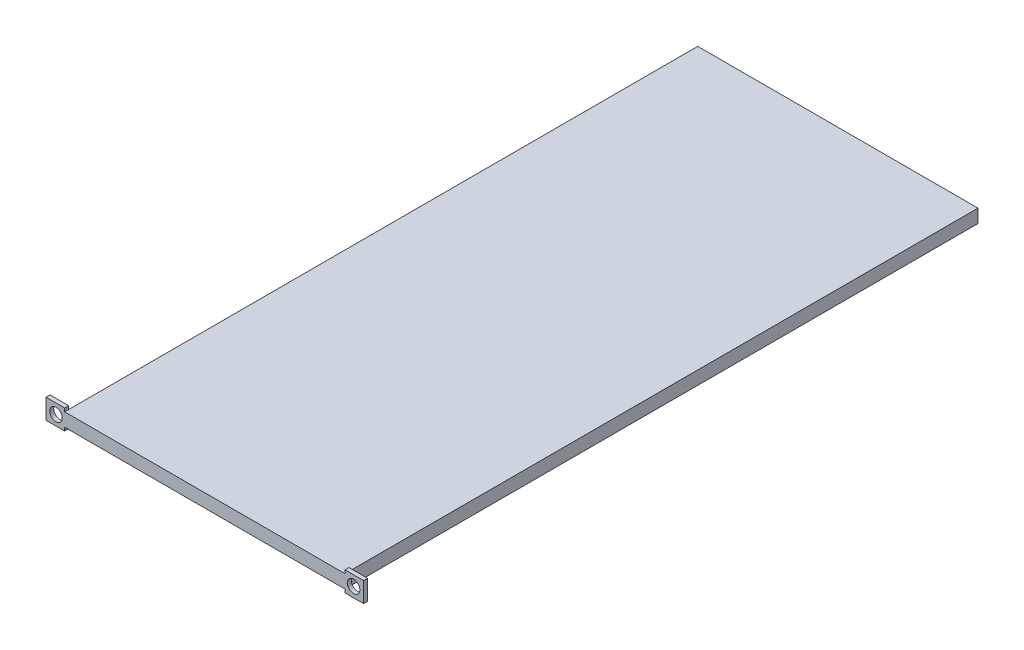
from build123d import *

# Parameters (mm, degrees)
SKETCH1_W           = 210.29
SKETCH1_H           = 10
BOSS_EXTRUDE1_DEPTH = 475
SKETCH2_W           = 3
SKETCH2_H           = 15
BOSS_EXTRUDE2_DEPTH = 14
SKETCH4_W           = 3
SKETCH4_H           = 15
BOSS_EXTRUDE3_DEPTH = 14
SKETCH3_R           = 4.7
CUT_EXTRUDE1_DEPTH  = 13


with BuildPart() as part:
    # Sketch1 → Boss-Extrude1 (new body)
    with BuildSketch(Plane.XY):
        with Locations((105.145, 5)):
            Rectangle(SKETCH1_W, SKETCH1_H)
    extrude(amount=BOSS_EXTRUDE1_DEPTH)

    # Sketch2 → Boss-Extrude2 (add)
    with BuildSketch(Plane.ZY):
        with Locations((473.5, 5)):
            Rectangle(SKETCH2_W, SKETCH2_H)
    extrude(amount=BOSS_EXTRUDE2_DEPTH)

    # Sketch4 → Boss-Extrude3 (add)
    with BuildSketch(Plane(origin=(210.29, 0, 0), x_dir=(0, 0, -1), z_dir=(1, 0, 0))):
        with Locations((-473.5, 5)):
            Rectangle(SKETCH4_W, SKETCH4_H)
    extrude(amount=BOSS_EXTRUDE3_DEPTH)

    # Sketch3 → Cut-Extrude1 (cut)
    with BuildSketch(Plane(origin=(0, 0, 472), x_dir=(-1, 0, 0), z_dir=(0, 0, -1))):
        with Locations((6.5, 5)):
            Circle(SKETCH3_R)
        with Locations((-216.79, 5)):
            Circle(SKETCH3_R)
    extrude(amount=-CUT_EXTRUDE1_DEPTH, mode=Mode.SUBTRACT)


solid = part.part
